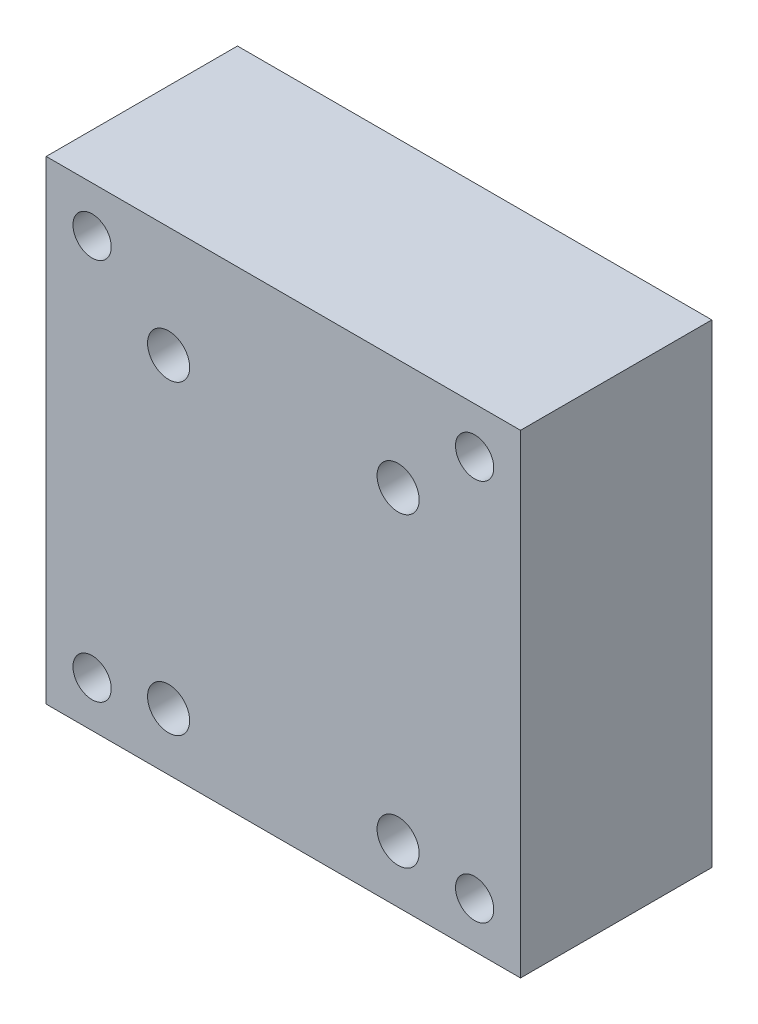
from build123d import *

# Parameters (mm, degrees)
SKETCH_1_W                   = 62
SKETCH_1_H                   = 62
EXTRUDE_1_DEPTH              = 25
HOLE_WIZARD_M6_1_D           = 5
HOLE_WIZARD_M5_1_D           = 5.5
HOLE_WIZARD_M5_1_CBORE_D     = 10
HOLE_WIZARD_M5_1_CBORE_DEPTH = 20


with BuildPart() as part:
    # 草图1 → 凸台-拉伸1 (new body)
    with BuildSketch(Plane.XY):
        Rectangle(SKETCH_1_W, SKETCH_1_H)
    extrude(amount=EXTRUDE_1_DEPTH)

    # M6 螺纹孔1 (through all)
    with Locations(Plane(origin=(25, 25, 0), x_dir=(-1, 0, 0), z_dir=(0, 0, -1))):
        with Locations((0, 0), (50, 0), (0, -50), (50, -50)):
            Hole(HOLE_WIZARD_M6_1_D / 2)

    # M5 六角凹头螺钉的柱形沉头孔1 (through all)
    with Locations(Plane(origin=(15, 16.5, 0), x_dir=(-1, 0, 0), z_dir=(0, 0, -1))):
        with Locations((0, 0), (30, 0), (30, -40), (0, -40)):
            CounterBoreHole(HOLE_WIZARD_M5_1_D / 2, HOLE_WIZARD_M5_1_CBORE_D / 2, HOLE_WIZARD_M5_1_CBORE_DEPTH)


solid = part.part
